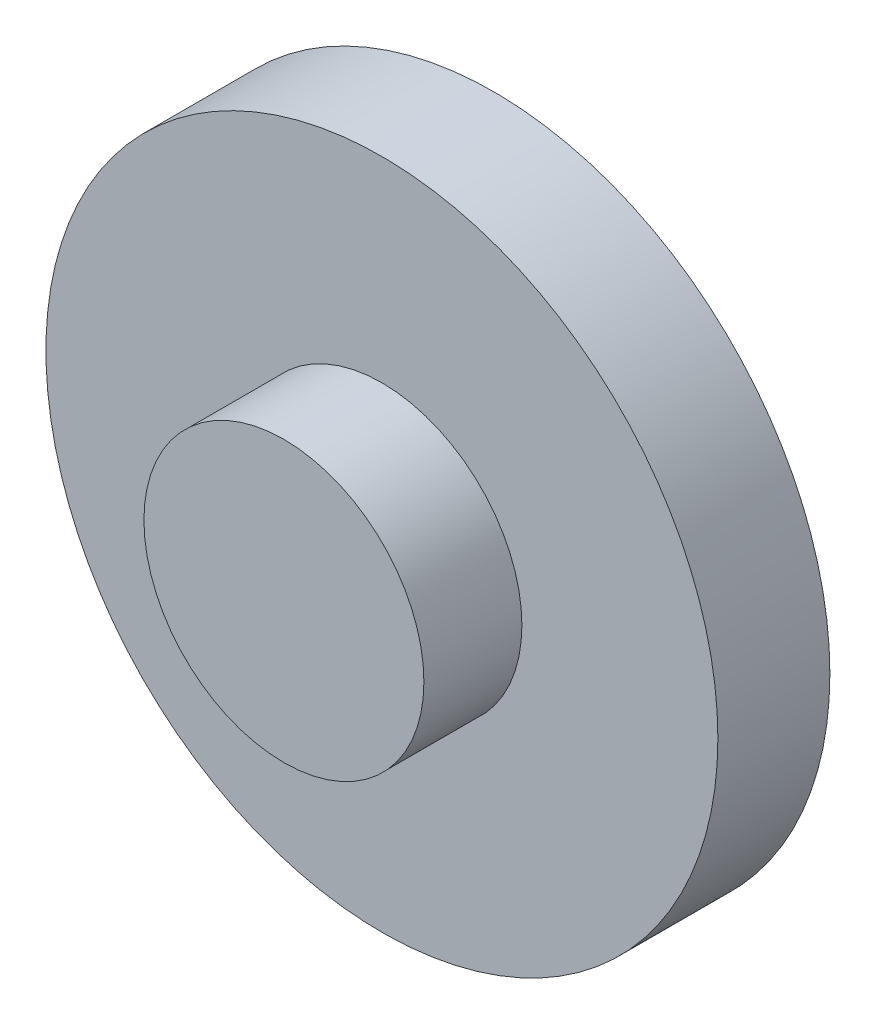
from build123d import *

# Parameters (mm, degrees)
SKETCH1_R           = 76.2
SKETCH1_R_2         = 15.875
BOSS_EXTRUDE1_DEPTH = 25.4
SKETCH2_R           = 31.75
BOSS_EXTRUDE2_DEPTH = 22.225


with BuildPart() as part:
    # Sketch1 → Boss-Extrude1 (new body)
    with BuildSketch(Plane.XY):
        Circle(SKETCH1_R)
        Circle(SKETCH1_R_2, mode=Mode.SUBTRACT)
    extrude(amount=BOSS_EXTRUDE1_DEPTH)

    # Sketch2 → Boss-Extrude2 (add)
    with BuildSketch(Plane.XY.offset(25.4)):
        Circle(SKETCH2_R)
    extrude(amount=BOSS_EXTRUDE2_DEPTH)


solid = part.part
